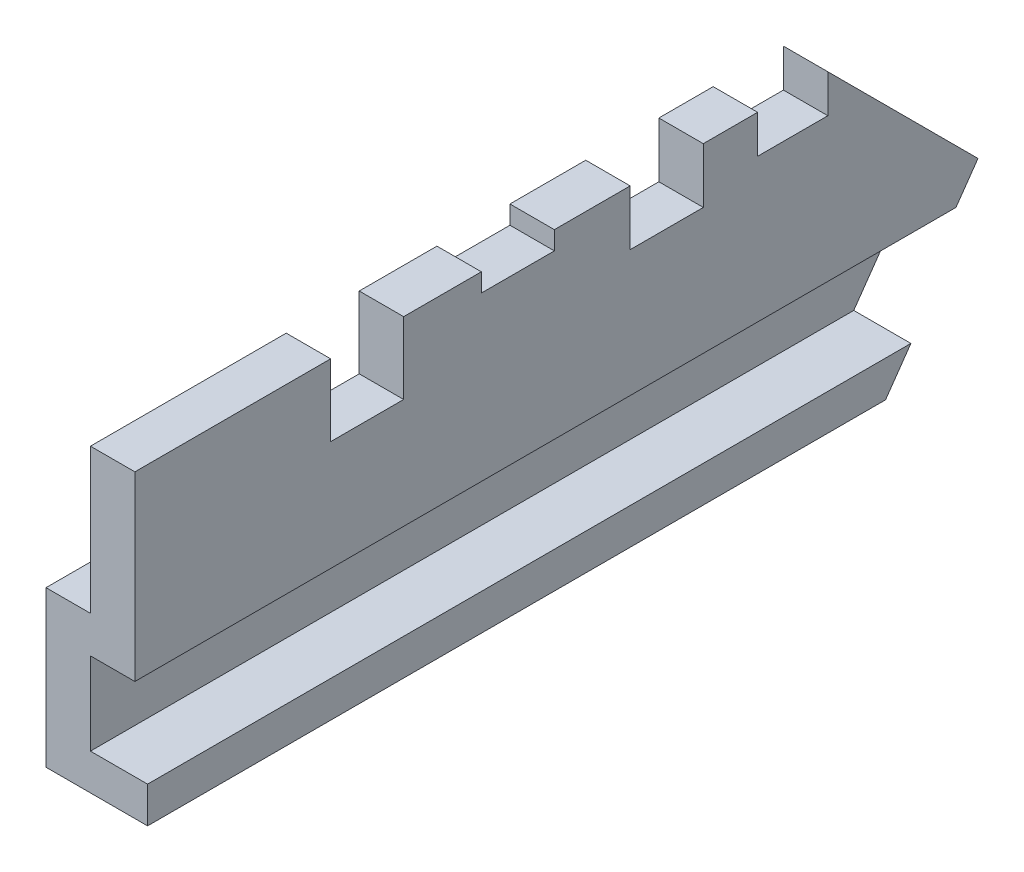
from build123d import *

# Parameters (mm, degrees)
BOSS_EXTRUDE1_DEPTH     = 13.28
CUT_EXTRUDE1_DEPTH      = 14.53406443
CUT_EXTRUDE1_DEPTH_BACK = 14.53406443
CUT_EXTRUDE5_DEPTH      = 0.29
CUT_EXTRUDE6_DEPTH      = 1.13
CUT_EXTRUDE7_DEPTH      = 0.87
CUT_EXTRUDE8_DEPTH      = 0.6


with BuildPart() as part:
    # Sketch1 → Boss-Extrude1 (new body)
    with BuildSketch(Plane.XY):
        Polygon((0, 0), (0, 2.28), (0.7, 2.28), (0.7, -0.58), (0, -0.58), (0, -1.88), (0.9, -1.88), (0.9, -2.45), (-0.7, -2.45), (-0.7, 0), align=None)
    extrude(amount=BOSS_EXTRUDE1_DEPTH)

    # Sketch2 → Cut-Extrude1 (cut, two sides)
    with BuildSketch(Plane(origin=(0, 0, 0), x_dir=(0, 0, -1), z_dir=(1, 0, 0))) as cut_extrude1_sk:
        Polygon((0.8, -2.75), (0.8, -0.085), (0.8, 2.58), (-2.665, 2.58), (0, -0.085), (-1.866053089, -2.75), align=None)
    extrude(amount=CUT_EXTRUDE1_DEPTH, mode=Mode.SUBTRACT)
    extrude(cut_extrude1_sk.sketch, amount=-CUT_EXTRUDE1_DEPTH_BACK, mode=Mode.SUBTRACT)

    # 3DSketch1 → Cut-Extrude5 (cut)
    with BuildSketch(Plane(origin=(0.7, 2.28, 7.8225), x_dir=(-0.5199469468957453, 0, -0.8541985556144386), z_dir=(0, 1, 0))):
        Polygon((0, 0), (0.982328339, -0.597938989), (1.346291202, 0), (0.363962863, 0.597938989), align=None)
    extrude(amount=-CUT_EXTRUDE5_DEPTH, mode=Mode.SUBTRACT)

    # 3DSketch1_3 → Cut-Extrude6 (cut)
    with BuildSketch(Plane(origin=(0, 2.28, 10.196397445), x_dir=(0.5199469468957453, 0, -0.8541985556144386), z_dir=(0, 1, 0))):
        Polygon((0, 0), (0.982328339, 0.597938989), (1.346291202, 0), (0.363962863, -0.597938989), align=None)
    extrude(amount=-CUT_EXTRUDE6_DEPTH, mode=Mode.SUBTRACT)

    # 3DSketch1_4 → Cut-Extrude7 (cut)
    with BuildSketch(Plane(origin=(0, 2.28, 5.478611146), x_dir=(0.519345577670118, 0, -0.8545643164528294), z_dir=(0, 1, 0))):
        Polygon((0, 0), (0.984308217, 0.598195022), (1.347850122, 0), (0.363541904, -0.598195022), align=None)
    extrude(amount=-CUT_EXTRUDE7_DEPTH, mode=Mode.SUBTRACT)

    # 3DSketch1_5 → Cut-Extrude8 (cut)
    with BuildSketch(Plane(origin=(0, 2.28, 3.471184381), x_dir=(0.5347339426738265, 0, -0.8450204793686985), z_dir=(0, 1, 0))):
        Polygon((0, 0), (0.934748456, 0.591514336), (1.309062216, 0), (0.37431376, -0.591514336), align=None)
    extrude(amount=-CUT_EXTRUDE8_DEPTH, mode=Mode.SUBTRACT)


solid = part.part
